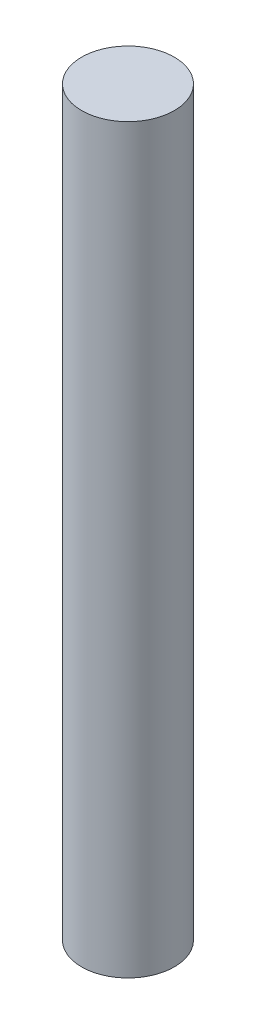
from build123d import *

# Parameters (mm, degrees)
SKETCH1_R           = 9.525
BOSS_EXTRUDE1_DEPTH = 152.4


with BuildPart() as part:
    # Sketch1 → Boss-Extrude1 (new body)
    with BuildSketch(Plane(origin=(0, 0, 0), x_dir=(1, 0, 0), z_dir=(0, 1, 0))):
        Circle(SKETCH1_R)
    extrude(amount=BOSS_EXTRUDE1_DEPTH)


solid = part.part
